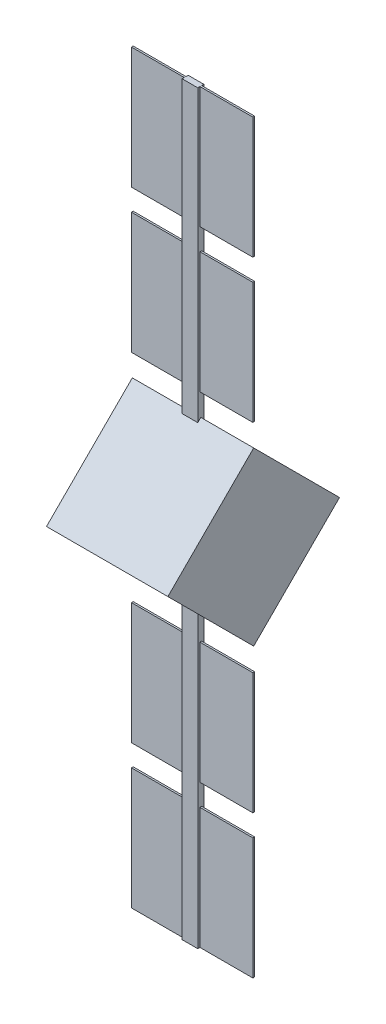
from build123d import *

# Parameters (mm, degrees)
SCHIZZO1_W                   = 700
SCHIZZO1_H                   = 700
ESTRUSIONE_ESTRUSIONE1_DEPTH = 350
SCHIZZO4_W                   = 90
SCHIZZO4_H                   = 35
ESTRUSIONE_ESTRUSIONE2_DEPTH = 2150
SCHIZZO6_W                   = 700
SCHIZZO6_H                   = 700
ESTRUSIONE_ESTRUSIONE3_DEPTH = 5
SCHIZZO7_W                   = 700
SCHIZZO7_H                   = 700
ESTRUSIONE_ESTRUSIONE4_DEPTH = 5
CORPO_SPOSTA_COPIA1_ANGLE    = 98.421058118


with BuildPart() as part:
    # Schizzo1 → Estrusione-Estrusione1 (new, symmetric)
    with BuildSketch(Plane(origin=(0, 0, 0), x_dir=(1, 0, 0), z_dir=(0, 1, 0))):
        Rectangle(SCHIZZO1_W, SCHIZZO1_H)
    extrude(amount=ESTRUSIONE_ESTRUSIONE1_DEPTH, both=True)

    # Schizzo4 → Estrusione-Estrusione2 (add, symmetric)
    with BuildSketch(Plane(origin=(0, 0, 0), x_dir=(0, -1, 0), z_dir=(-0.7071067811865488, 0, 0.7071067811865464))):
        Rectangle(SCHIZZO4_W, SCHIZZO4_H)
    extrude(amount=ESTRUSIONE_ESTRUSIONE2_DEPTH, both=True)

    # Schizzo6 → Estrusione-Estrusione3 (add, symmetric)
    with BuildSketch(Plane(origin=(0, 0, 0), x_dir=(0, -1, 0), z_dir=(0.7071067811865488, 0, 0.7071067811865464))):
        with Locations((0, -974.974746831)):
            Rectangle(SCHIZZO6_W, SCHIZZO6_H)
    estrusione_estrusione3 = extrude(amount=ESTRUSIONE_ESTRUSIONE3_DEPTH, both=True)

    # Schizzo7 → Estrusione-Estrusione4 (add, symmetric)
    with BuildSketch(Plane(origin=(0, 0, 0), x_dir=(0, -1, 0), z_dir=(0.7071067811865488, 0, 0.7071067811865464))):
        with Locations((0, -1800)):
            Rectangle(SCHIZZO7_W, SCHIZZO7_H)
    estrusione_estrusione4 = extrude(amount=ESTRUSIONE_ESTRUSIONE4_DEPTH, both=True)

    # Specchia1: Estrusione-Estrusione3, Estrusione-Estrusione4 across plane
    add(estrusione_estrusione3.mirror(Plane(origin=(0, 0, 0), x_dir=(0.7071067811865465, 0, 0.7071067811865486), z_dir=(-0.7071067811865488, 0, 0.7071067811865464))))
    add(estrusione_estrusione4.mirror(Plane(origin=(0, 0, 0), x_dir=(0.7071067811865465, 0, 0.7071067811865486), z_dir=(-0.7071067811865488, 0, 0.7071067811865464))))


with BuildPart() as part_1:
    # Corpo-Sposta_copia1: moved
    add(part.part.rotate(Axis((0, 0, 0), (0.3574067443365941, -0.3574067443365928, 0.8628562094610166)), CORPO_SPOSTA_COPIA1_ANGLE))


solid = part_1.part
